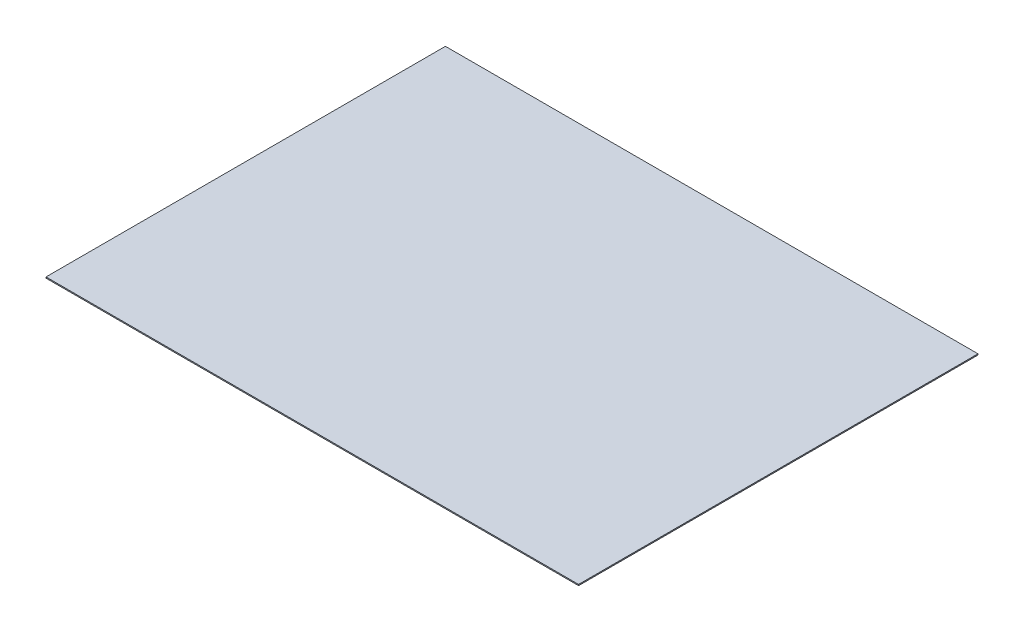
from build123d import *

# Parameters (mm, degrees)
SKETCH1_W           = 1219.2
SKETCH1_H           = 914.4
BOSS_EXTRUDE1_DEPTH = 2.54


with BuildPart() as part:
    # Sketch1 → Boss-Extrude1 (new body)
    with BuildSketch(Plane(origin=(0, 0, 0), x_dir=(1, 0, 0), z_dir=(0, 1, 0))):
        with Locations((609.6, 457.2)):
            Rectangle(SKETCH1_W, SKETCH1_H)
    extrude(amount=BOSS_EXTRUDE1_DEPTH)


solid = part.part
